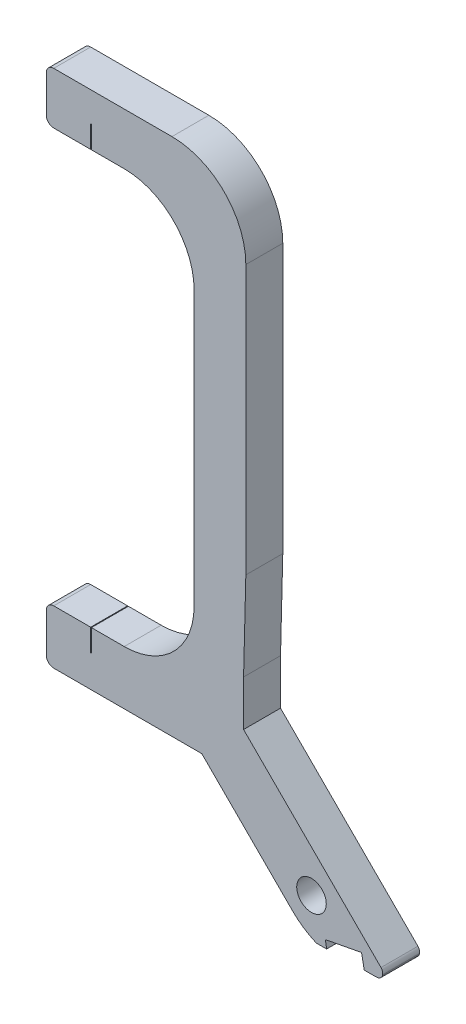
from build123d import *

# Parameters (mm, degrees)
SKETCH1_R           = 2
BOSS_EXTRUDE1_DEPTH = 5
SKETCH2_W           = 0.1
SKETCH2_H           = 5
CUT_EXTRUDE1_DEPTH  = 3
SKETCH3_W           = 0.1
SKETCH3_H           = 5
CUT_EXTRUDE2_DEPTH  = 3
SKETCH5_W           = 5
SKETCH5_H           = 5
CUT_EXTRUDE3_DEPTH  = 3


with BuildPart() as part:
    # Sketch1 → Boss-Extrude1 (new body)
    with BuildSketch(Plane.XY):
        with BuildLine():
            Line((1, 0), (17, 0))
            ThreePointArc((17, 0), (24.071067812, -2.928932188), (27, -10))
            Line((27, -10), (27, -10.164726931))
            Line((27, -10.164726931), (27, -46.377180563))
            Line((27, -46.377180563), (26.694646109, -58.493944172))
            Line((26.694646109, -58.493944172), (26.694646109, -64.399649032))
            Line((26.694646109, -64.399649032), (26.694646109, -64.648499642))
            Line((26.694646109, -64.648499642), (45.291824906, -83.245678439))
            ThreePointArc((45.291824906, -83.245678439), (45.495822693, -83.59321769), (45.504515015, -83.996111065))
            Line((45.504515015, -83.996111065), (45.490365745, -84.055724665))
            ThreePointArc((45.490365745, -84.055724665), (45.211760066, -84.495661458), (44.721403846, -84.670922077))
            Line((44.721403846, -84.670922077), (36.743309345, -84.764807165))
            ThreePointArc((36.743309345, -84.764807165), (36.575585477, -84.749042296), (36.414881636, -84.698504168))
            ThreePointArc((36.414881636, -84.698504168), (34.774424803, -83.79382462), (33.33148975, -82.599051781))
            Line((33.33148975, -82.599051781), (21.037791859, -70.305353891))
            Line((21.037791859, -70.305353891), (16.801941123, -70.305353891))
            Line((16.801941123, -70.305353891), (1, -70.305353891))
            ThreePointArc((1, -70.305353891), (0.292893219, -70.012460672), (0, -69.305353891))
            Line((0, -69.305353891), (0, -64))
            ThreePointArc((0, -64), (0.292893219, -63.292893219), (1, -63))
            Line((1, -63), (10.539737479, -63))
            ThreePointArc((10.539737479, -63), (17.229153259, -60.229153259), (20, -53.539737479))
            Line((20, -53.539737479), (20, -16.460262521))
            ThreePointArc((20, -16.460262521), (17.229153259, -9.770846741), (10.539737479, -7))
            Line((10.539737479, -7), (1, -7))
            ThreePointArc((1, -7), (0.292893219, -6.707106781), (0, -6))
            Line((0, -6), (0, -1))
            ThreePointArc((0, -1), (0.292893219, -0.292893219), (1, 0))
        make_face()
        with Locations((35.887034264, -79.497742046)):
            Circle(SKETCH1_R, mode=Mode.SUBTRACT)
    extrude(amount=BOSS_EXTRUDE1_DEPTH)

    # Sketch2 → Cut-Extrude1 (cut)
    with BuildSketch(Plane(origin=(0, -63, 0), x_dir=(1, 0, 0), z_dir=(0, 1, 0))):
        with Locations((6.05, -2.5)):
            Rectangle(SKETCH2_W, SKETCH2_H)
    extrude(amount=-CUT_EXTRUDE1_DEPTH, mode=Mode.SUBTRACT)

    # Sketch3 → Cut-Extrude2 (cut)
    with BuildSketch(Plane.XZ.offset(7)):
        with Locations((6.05, 2.5)):
            Rectangle(SKETCH3_W, SKETCH3_H)
    extrude(amount=-CUT_EXTRUDE2_DEPTH, mode=Mode.SUBTRACT)

    # Sketch5 → Cut-Extrude3 (cut)
    with BuildSketch(Plane(origin=(17.315374744, -90.697945443, 0), x_dir=(0, 0, -1), z_dir=(0.18752569, -0.982259699, 0))):
        with Locations((-2.5, 23.878338891)):
            Rectangle(SKETCH5_W, SKETCH5_H)
    extrude(amount=-CUT_EXTRUDE3_DEPTH, mode=Mode.SUBTRACT)


solid = part.part
